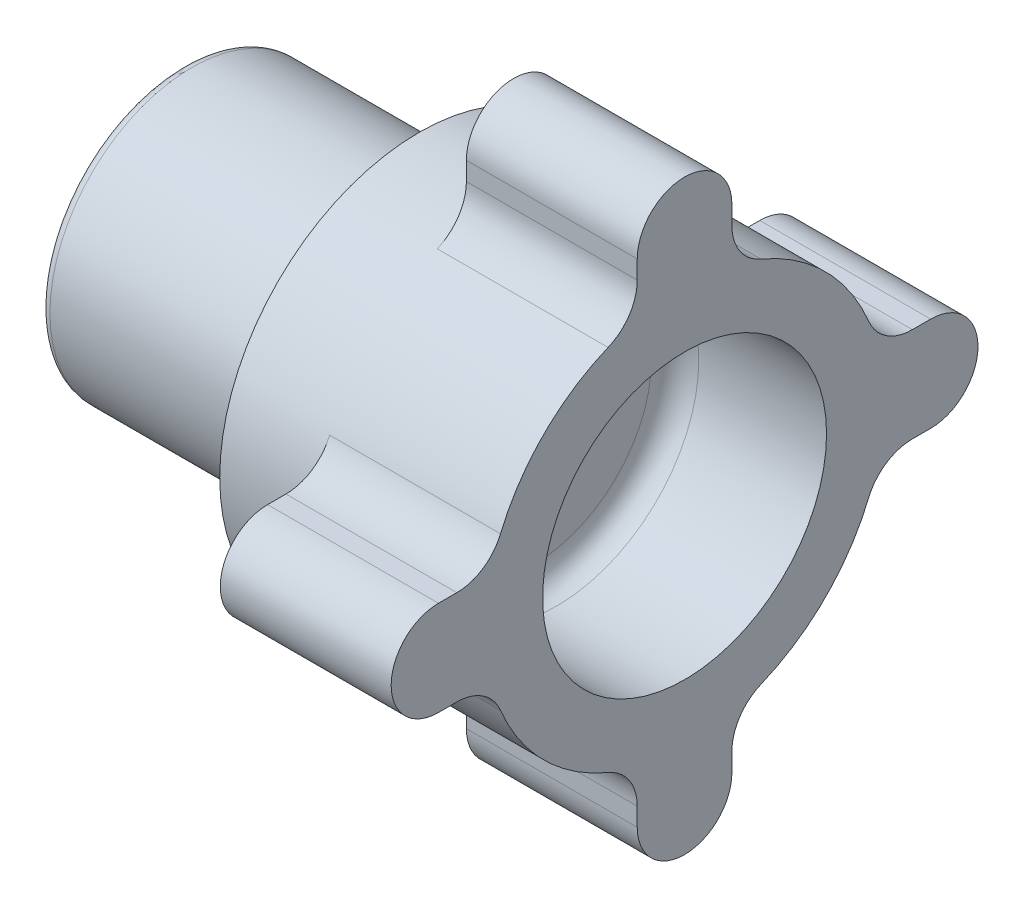
from build123d import *

# Parameters (mm, degrees)
F_3_16_0_1875_DOWEL_HOLE1_D     = 4.7625
F_3_16_0_1875_DOWEL_HOLE1_DEPTH = 12.7
F_3_16_0_1875_DOWEL_HOLE1_TIP   = 1.430799
CUT_EXTRUDE3_DEPTH              = 22.925
SKETCH6_R                       = 19.05
CUT_EXTRUDE4_DEPTH              = 20.32
FILLET8_R                       = 6.35
FILLET7_R                       = 1.27
FILLET9_R                       = 3.175
F_1_4_20_TAPPED_HOLE1_D         = 5.1054
F_1_4_20_TAPPED_HOLE1_DEPTH     = 16.51
F_1_4_20_TAPPED_HOLE1_TIP       = 1.533817


with BuildPart() as part:
    # Sketch1 → Revolve1 (revolve)
    with BuildSketch(Plane.XY):
        Polygon((479.941353, 251.46), (511.691353, 251.46), (511.691353, 259.155045), (524.391353, 259.155045), (524.391353, 271.78), (547.316353, 271.78), (547.316353, 238.76), (479.941353, 238.76), align=None)
    revolve(axis=Axis((439.541353, 232.41, 0), (1, 0, 0)))

    # 3/16 (0.1875) Dowel Hole1
    with Locations(Plane(origin=(479.941353, 238.76, -10.998523), x_dir=(0, 0, -1), z_dir=(-1, 0, 0))):
        with Locations((0, 0), (-10.998523, -6.35), (-21.997045, 0), (-21.997045, 12.7), (-10.998523, 19.05), (0, 12.7)):
            Hole(F_3_16_0_1875_DOWEL_HOLE1_D / 2, depth=F_3_16_0_1875_DOWEL_HOLE1_DEPTH)
            with Locations((0, 0, -(F_3_16_0_1875_DOWEL_HOLE1_DEPTH + F_3_16_0_1875_DOWEL_HOLE1_TIP / 2))):  # 118° drill point
                Cone(0, F_3_16_0_1875_DOWEL_HOLE1_D / 2, F_3_16_0_1875_DOWEL_HOLE1_TIP, mode=Mode.SUBTRACT)

    # Sketch5 → Cut-Extrude3 (cut)
    with BuildSketch(Plane.ZY.offset(-524.391353)):
        with BuildLine():
            ThreePointArc((-33.02, 226.06), (-37.510128, 227.919872), (-39.37, 232.41))
            ThreePointArc((-39.37, 232.41), (-27.838794, 204.571206), (0, 193.04))
            ThreePointArc((0, 193.04), (-4.490128, 194.899872), (-6.35, 199.39))
            Line((-6.35, 199.39), (-6.35, 206.42972))
            ThreePointArc((-6.35, 206.42972), (-18.911603, 213.498397), (-25.98028, 226.06))
            Line((-25.98028, 226.06), (-33.02, 226.06))
        make_face()
        with BuildLine():
            Line((-6.35, 258.39028), (-6.35, 265.43))
            ThreePointArc((-6.35, 265.43), (-4.490128, 269.920128), (0, 271.78))
            ThreePointArc((0, 271.78), (-27.838794, 260.248794), (-39.37, 232.41))
            ThreePointArc((-39.37, 232.41), (-37.510128, 236.900128), (-33.02, 238.76))
            Line((-33.02, 238.76), (-25.98028, 238.76))
            ThreePointArc((-25.98028, 238.76), (-18.911603, 251.321603), (-6.35, 258.39028))
        make_face()
        with BuildLine():
            ThreePointArc((39.37, 232.41), (27.838794, 260.248794), (0, 271.78))
            ThreePointArc((0, 271.78), (4.490128, 269.920128), (6.35, 265.43))
            Line((6.35, 265.43), (6.35, 258.39028))
            ThreePointArc((6.35, 258.39028), (18.911603, 251.321603), (25.98028, 238.76))
            Line((25.98028, 238.76), (33.02, 238.76))
            ThreePointArc((33.02, 238.76), (37.510128, 236.900128), (39.37, 232.41))
        make_face()
        with BuildLine():
            ThreePointArc((0, 193.04), (27.838794, 204.571206), (39.37, 232.41))
            ThreePointArc((39.37, 232.41), (37.510128, 227.919872), (33.02, 226.06))
            Line((33.02, 226.06), (25.98028, 226.06))
            ThreePointArc((25.98028, 226.06), (18.911603, 213.498397), (6.35, 206.42972))
            Line((6.35, 206.42972), (6.35, 199.39))
            ThreePointArc((6.35, 199.39), (4.490128, 194.899872), (0, 193.04))
        make_face()
    extrude(amount=-CUT_EXTRUDE3_DEPTH, mode=Mode.SUBTRACT)

    # Sketch6 → Cut-Extrude4 (cut)
    with BuildSketch(Plane(origin=(547.316353, 0, 0), x_dir=(0, 0, -1), z_dir=(1, 0, 0))):
        with Locations((0, 232.41)):
            Circle(SKETCH6_R)
    extrude(amount=-CUT_EXTRUDE4_DEPTH, mode=Mode.SUBTRACT)

    # Fillet8
    fillet8_edges = [part.edges().sort_by_distance(p)[0] for p in [
        (535.853853, 226.06, 25.98028),
        (535.853853, 206.42972, 6.35),
        (535.853853, 206.42972, -6.35),
        (535.853853, 226.06, -25.98028),
        (535.853853, 238.76, -25.98028),
        (535.853853, 258.39028, -6.35),
        (535.853853, 258.39028, 6.35),
        (535.853853, 238.76, 25.98028),
    ]]
    fillet(fillet8_edges, radius=FILLET8_R)

    # Fillet7
    fillet7_edges = [part.edges().sort_by_distance(p)[0] for p in [
        (479.941353, 226.06, 0),
        (479.941353, 213.36, 0),
    ]]
    fillet(fillet7_edges, radius=FILLET7_R)

    # Fillet9
    fillet9_edges = [part.edges().sort_by_distance(p)[0] for p in [
        (526.996353, 232.41, 19.05),
    ]]
    fillet(fillet9_edges, radius=FILLET9_R)

    # 1/4-20 Tapped Hole1
    with Locations(Plane(origin=(524.391353, 232.41, -34.29), x_dir=(0, 0, -1), z_dir=(-1, 0, 0))):
        with Locations((0, 0), (-34.29, -34.29), (-68.58, 0), (-34.29, 34.29)):
            Hole(F_1_4_20_TAPPED_HOLE1_D / 2, depth=F_1_4_20_TAPPED_HOLE1_DEPTH)
            with Locations((0, 0, -(F_1_4_20_TAPPED_HOLE1_DEPTH + F_1_4_20_TAPPED_HOLE1_TIP / 2))):  # 118° drill point
                Cone(0, F_1_4_20_TAPPED_HOLE1_D / 2, F_1_4_20_TAPPED_HOLE1_TIP, mode=Mode.SUBTRACT)


solid = part.part
